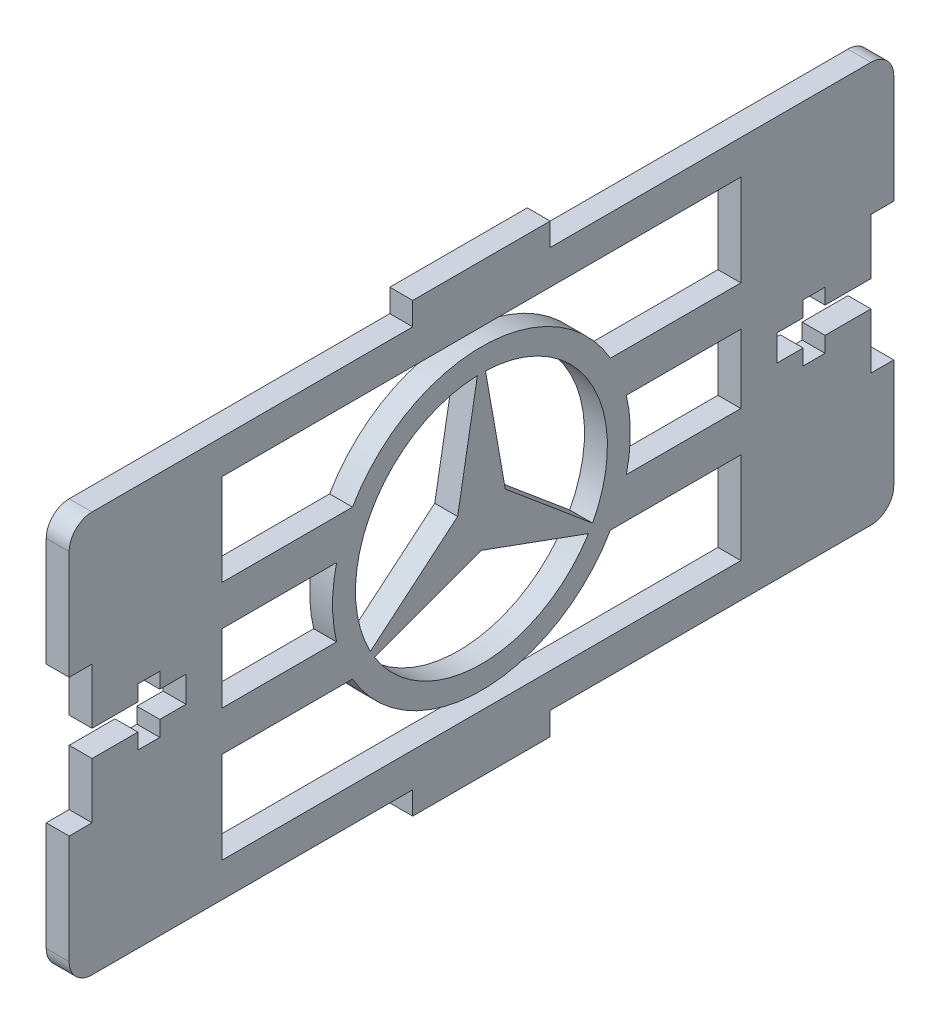
from build123d import *

# Parameters (mm, degrees)
BOSS_EXTRUDE1_DEPTH = 2.54
FILLET1_R           = 2.54
CUT_EXTRUDE2_REACH  = 4.54
CUT_EXTRUDE3_DEPTH  = 2.54


with BuildPart() as part:
    # Sketch2 → Boss-Extrude1 (new body)
    with BuildSketch(Plane(origin=(0, 0, 0), x_dir=(0, 0, -1), z_dir=(1, 0, 0))):
        Polygon((-45.72, 22.225), (-45.72, 7.62), (-43.18, 7.62), (-43.18, 1.4478), (-38.1, 1.4478), (-38.1, 3.175), (-35.66795, 3.175), (-35.66795, 1.4478), (-32.766, 1.4478), (-32.766, -1.4478), (-35.66795, -1.4478), (-35.66795, -3.175), (-38.1, -3.175), (-38.1, -1.4478), (-43.18, -1.4478), (-43.18, -7.62), (-45.72, -7.62), (-45.72, -22.225), (-7.62, -22.225), (-7.62, -24.765), (7.62, -24.765), (7.62, -22.225), (45.72, -22.225), (45.72, -7.62), (43.18, -7.62), (43.18, -1.4478), (38.1, -1.4478), (38.1, -3.175), (35.66795, -3.175), (35.66795, -1.4478), (32.766, -1.4478), (32.766, 1.4478), (35.66795, 1.4478), (35.66795, 3.175), (38.1, 3.175), (38.1, 1.4478), (43.18, 1.4478), (43.18, 7.62), (45.72, 7.62), (45.72, 22.225), (7.62, 22.225), (7.62, 24.765), (-7.62, 24.765), (-7.62, 22.225), align=None)
    extrude(amount=BOSS_EXTRUDE1_DEPTH)

    # Fillet1
    fillet1_edges = [part.edges().sort_by_distance(p)[0] for p in [
        (1.27, -22.225, -45.72),
        (1.27, -22.225, 45.72),
        (1.27, 22.225, 45.72),
        (1.27, 22.225, -45.72),
    ]]
    fillet(fillet1_edges, radius=FILLET1_R)

    # Sketch3 → Cut-Extrude2 (cut, up to next)
    with BuildSketch(Plane(origin=(2.54, 0, 0), x_dir=(0, 0, -1), z_dir=(1, 0, 0)), mode=Mode.PRIVATE) as cut_extrude2_sk1:
        with BuildLine():
            Line((2.639645431, 1.524), (12.316467203, -6.592839725))
            ThreePointArc((12.316467203, -6.592839725), (12.098374891, 6.985), (0.448666916, 13.962793345))
            Line((0.448666916, 13.962793345), (2.639645431, 1.524))
        make_face()
    cut_extrude2_tool1 = extrude(cut_extrude2_sk1.sketch, amount=-CUT_EXTRUDE2_REACH, mode=Mode.PRIVATE) & part.part
    add(cut_extrude2_tool1.solids().sort_by_distance((2.54, 4.379888, -7.586189))[0], mode=Mode.SUBTRACT)
    # Sketch3 → Cut-Extrude2 (cut, up to next)
    with BuildSketch(Plane(origin=(2.54, 0, 0), x_dir=(0, 0, -1), z_dir=(1, 0, 0)), mode=Mode.PRIVATE) as cut_extrude2_sk2:
        with BuildLine():
            Line((0, -3.048), (11.867800287, -7.36995362))
            ThreePointArc((11.867800287, -7.36995362), (0, -13.97), (-11.867800287, -7.36995362))
            Line((-11.867800287, -7.36995362), (0, -3.048))
        make_face()
    cut_extrude2_tool2 = extrude(cut_extrude2_sk2.sketch, amount=-CUT_EXTRUDE2_REACH, mode=Mode.PRIVATE) & part.part
    add(cut_extrude2_tool2.solids().sort_by_distance((2.54, -8.759776, 0))[0], mode=Mode.SUBTRACT)
    # Sketch3 → Cut-Extrude2 (cut, up to next)
    with BuildSketch(Plane(origin=(2.54, 0, 0), x_dir=(0, 0, -1), z_dir=(1, 0, 0)), mode=Mode.PRIVATE) as cut_extrude2_sk3:
        with BuildLine():
            Line((-2.639645431, 1.524), (-0.448666916, 13.962793345))
            ThreePointArc((-0.448666916, 13.962793345), (-12.098374891, 6.985), (-12.316467203, -6.592839725))
            Line((-12.316467203, -6.592839725), (-2.639645431, 1.524))
        make_face()
    cut_extrude2_tool3 = extrude(cut_extrude2_sk3.sketch, amount=-CUT_EXTRUDE2_REACH, mode=Mode.PRIVATE) & part.part
    add(cut_extrude2_tool3.solids().sort_by_distance((2.54, 4.379888, 7.586189))[0], mode=Mode.SUBTRACT)

    # Sketch4 → Cut-Extrude3 (cut)
    with BuildSketch(Plane(origin=(2.54, 0, 0), x_dir=(0, 0, -1), z_dir=(1, 0, 0))):
        with BuildLine():
            Line((-28.764370514, 18.415), (28.764370514, 18.415))
            Line((28.764370514, 18.415), (28.764370514, 8.255))
            Line((28.764370514, 8.255), (14.298079416, 8.255))
            ThreePointArc((14.298079416, 8.255), (0, 16.51), (-14.298079416, 8.255))
            Line((-14.298079416, 8.255), (-28.764370514, 8.255))
            Line((-28.764370514, 8.255), (-28.764370514, 18.415))
        make_face()
        with BuildLine():
            Line((-28.764370514, -18.415), (-28.764370514, -8.255))
            Line((-28.764370514, -8.255), (-14.298079416, -8.255))
            ThreePointArc((-14.298079416, -8.255), (0, -16.51), (14.298079416, -8.255))
            Line((14.298079416, -8.255), (28.764370514, -8.255))
            Line((28.764370514, -8.255), (28.764370514, -18.415))
            Line((28.764370514, -18.415), (-28.764370514, -18.415))
        make_face()
        with BuildLine():
            Line((-16.064370514, 3.81), (-28.764370514, 3.81))
            Line((-28.764370514, 3.81), (-28.764370514, -3.81))
            Line((-28.764370514, -3.81), (-16.064370514, -3.81))
            ThreePointArc((-16.064370514, -3.81), (-16.51, 0), (-16.064370514, 3.81))
        make_face()
        with BuildLine():
            Line((28.764370514, -3.81), (16.064370514, -3.81))
            ThreePointArc((16.064370514, -3.81), (16.51, 0), (16.064370514, 3.81))
            Line((16.064370514, 3.81), (28.764370514, 3.81))
            Line((28.764370514, 3.81), (28.764370514, -3.81))
        make_face()
    extrude(amount=-CUT_EXTRUDE3_DEPTH, mode=Mode.SUBTRACT)


solid = part.part
